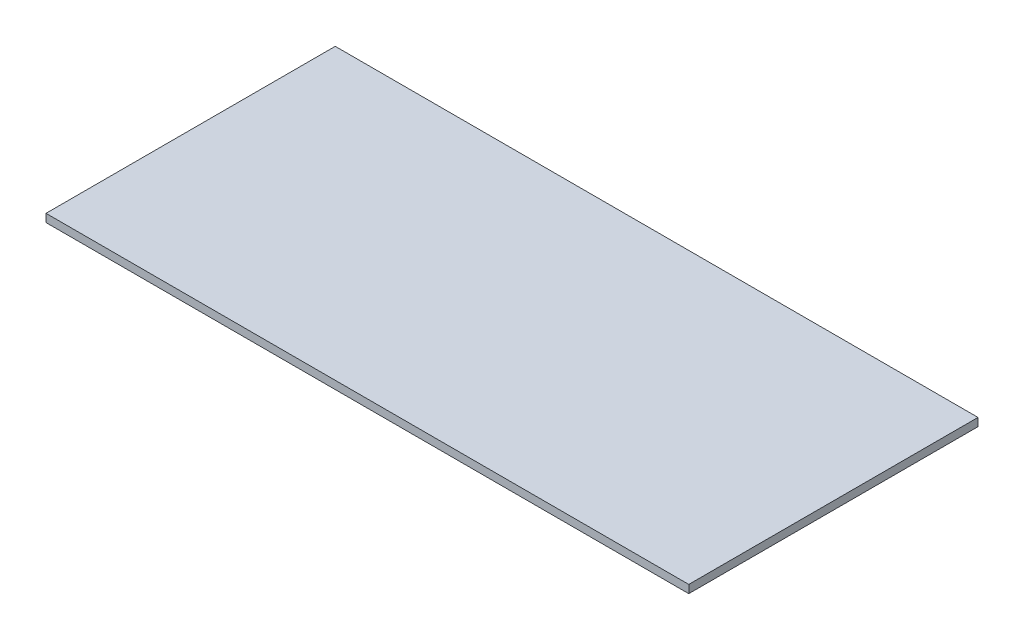
from build123d import *

# Parameters (mm, degrees)
SKETCH_1_W      = 800
SKETCH_1_H      = 360
EXTRUDE_1_DEPTH = 10


with BuildPart() as part:
    # Эскиз1 → Бобышка-Вытянуть1 (new body)
    with BuildSketch(Plane(origin=(0, 0, 0), x_dir=(1, 0, 0), z_dir=(0, 1, 0))):
        Rectangle(SKETCH_1_W, SKETCH_1_H)
    extrude(amount=EXTRUDE_1_DEPTH)


solid = part.part
